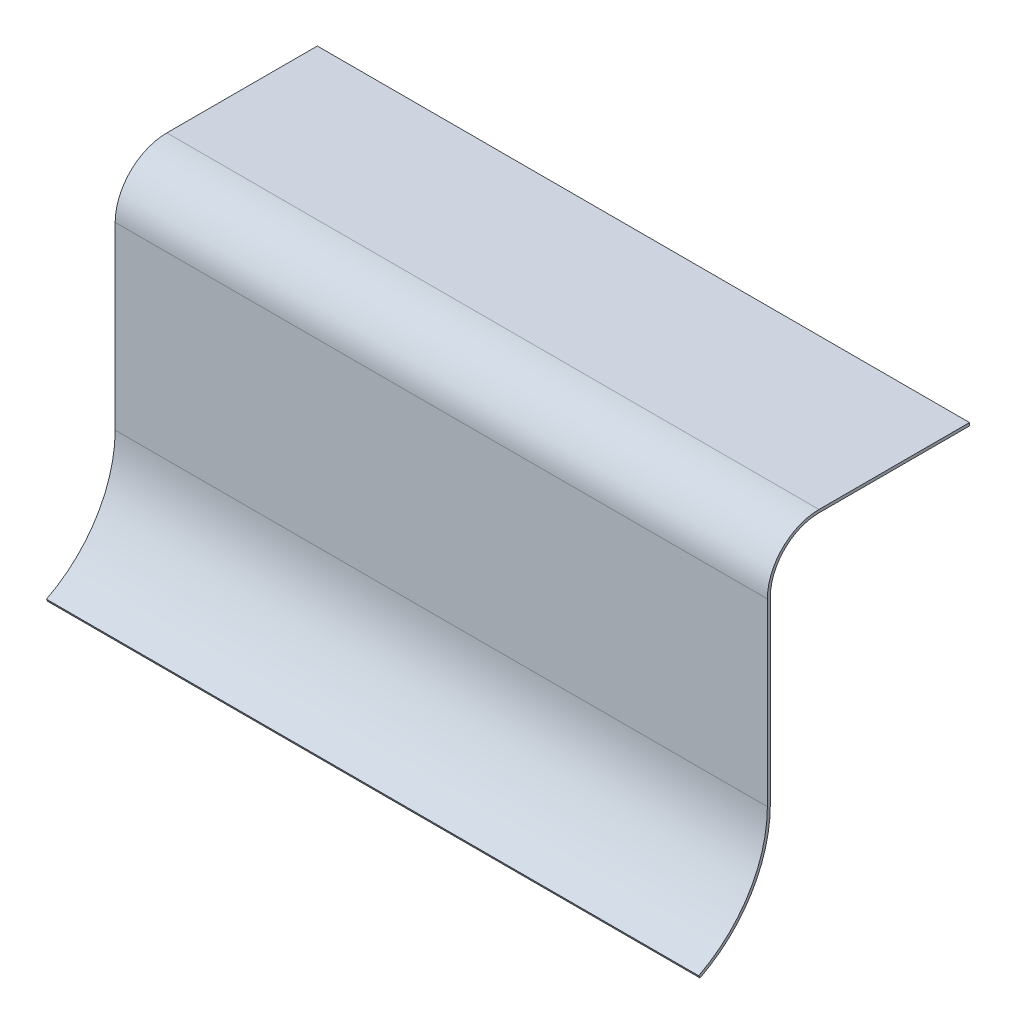
from build123d import *

# Parameters (mm, degrees)
EXTRUDE_THIN1_DEPTH = 165.1


with BuildPart() as part:
    # Sketch2 → Extrude-Thin1 (new body, symmetric)
    with BuildSketch(Plane(origin=(0, 0, 0), x_dir=(0, 0, -1), z_dir=(1, 0, 0))):
        with BuildLine():
            ThreePointArc((-60.240298086, -174.5682791), (-34.255387925, -150.550644745), (-24.65, -116.494825288))
            Line((-24.65, -116.494825288), (-24.65, -25.4))
            ThreePointArc((-24.65, -25.4), (-17.430182156, -7.969817844), (0, -0.75))
            Line((0, -0.75), (76.2, -0.75))
            Line((76.2, -0.75), (76.2, 0.75))
            Line((76.2, 0.75), (0, 0.75))
            ThreePointArc((0, 0.75), (-18.490842328, -6.909157672), (-26.15, -25.4))
            Line((-26.15, -25.4), (-26.15, -116.494825288))
            ThreePointArc((-26.15, -116.494825288), (-35.534320309, -149.766851432), (-60.921188809, -173.2317209))
            Line((-60.921188809, -173.2317209), (-60.240298086, -174.5682791))
        make_face()
    extrude(amount=EXTRUDE_THIN1_DEPTH, both=True)


solid = part.part
